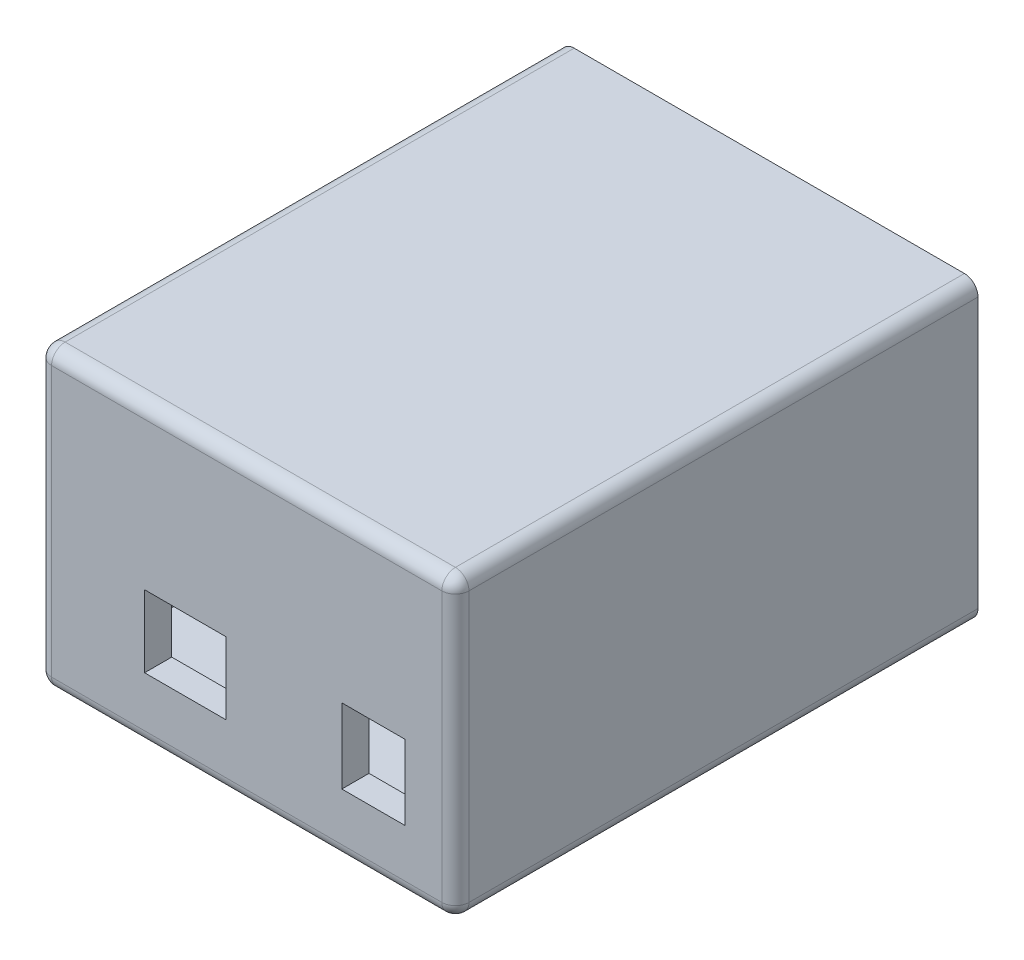
from build123d import *

# Parameters (mm, degrees)
ESQUISSE1_W             = 61.5
ESQUISSE1_H             = 43.75
BOSS_EXTRU_1_DEPTH      = 77
ENL_V_MAT_EXTRU_4_REACH = 79
ESQUISSE3_W             = 9.3
ESQUISSE3_H             = 11
ESQUISSE3_W_2           = 12
ESQUISSE3_H_2           = 10.6
ESQUISSE6_W             = 53.5
ESQUISSE6_H             = 35.75
ENL_V_MAT_EXTRU_5_DEPTH = 73
CONG_4_R                = 2


with BuildPart() as part:
    # Esquisse1 → Boss.-Extru.1 (new body)
    with BuildSketch(Plane.XY):
        with Locations((-0.850502513, 12.751256281)):
            Rectangle(ESQUISSE1_W, ESQUISSE1_H)
    extrude(amount=BOSS_EXTRU_1_DEPTH)

    # Esquisse3 → Enlèv. mat.-Extru.4 (cut, up to next)
    with BuildSketch(Plane.XY.offset(77), mode=Mode.PRIVATE) as enl_v_mat_extru_4_sk1:
        with Locations((17.819497487, 5.476256281)):
            Rectangle(ESQUISSE3_W, ESQUISSE3_H)
    enl_v_mat_extru_4_tool1 = extrude(enl_v_mat_extru_4_sk1.sketch, amount=-ENL_V_MAT_EXTRU_4_REACH, mode=Mode.PRIVATE) & part.part
    add(enl_v_mat_extru_4_tool1.solids().sort_by_distance((17.819497, 5.476256, 77))[0], mode=Mode.SUBTRACT)
    # Esquisse3 → Enlèv. mat.-Extru.4 (cut, up to next)
    with BuildSketch(Plane.XY.offset(77), mode=Mode.PRIVATE) as enl_v_mat_extru_4_sk2:
        with Locations((-9.900502513, 5.576256281)):
            Rectangle(ESQUISSE3_W_2, ESQUISSE3_H_2)
    enl_v_mat_extru_4_tool2 = extrude(enl_v_mat_extru_4_sk2.sketch, amount=-ENL_V_MAT_EXTRU_4_REACH, mode=Mode.PRIVATE) & part.part
    add(enl_v_mat_extru_4_tool2.solids().sort_by_distance((-9.900503, 5.576256, 77))[0], mode=Mode.SUBTRACT)

    # Esquisse6 → Enlèv. mat.-Extru.5 (cut)
    with BuildSketch(Plane(origin=(0, 0, 0), x_dir=(-1, 0, 0), z_dir=(0, 0, -1))):
        with Locations((0.850502513, 12.751256281)):
            Rectangle(ESQUISSE6_W, ESQUISSE6_H)
    extrude(amount=-ENL_V_MAT_EXTRU_5_DEPTH, mode=Mode.SUBTRACT)

    # Congé4
    cong_4_edges = [part.edges().sort_by_distance(p)[0] for p in [
        (29.899497487, 12.751256281, 77),
        (-0.850502513, 34.626256281, 77),
        (-31.600502513, 12.751256281, 77),
        (-31.600502513, 34.626256281, 38.5),
        (29.899497487, 34.626256281, 38.5),
        (29.899497487, -9.123743719, 38.5),
        (-31.600502513, -9.123743719, 38.5),
        (-0.850502513, -9.123743719, 77),
    ]]
    fillet(cong_4_edges, radius=CONG_4_R)


solid = part.part
